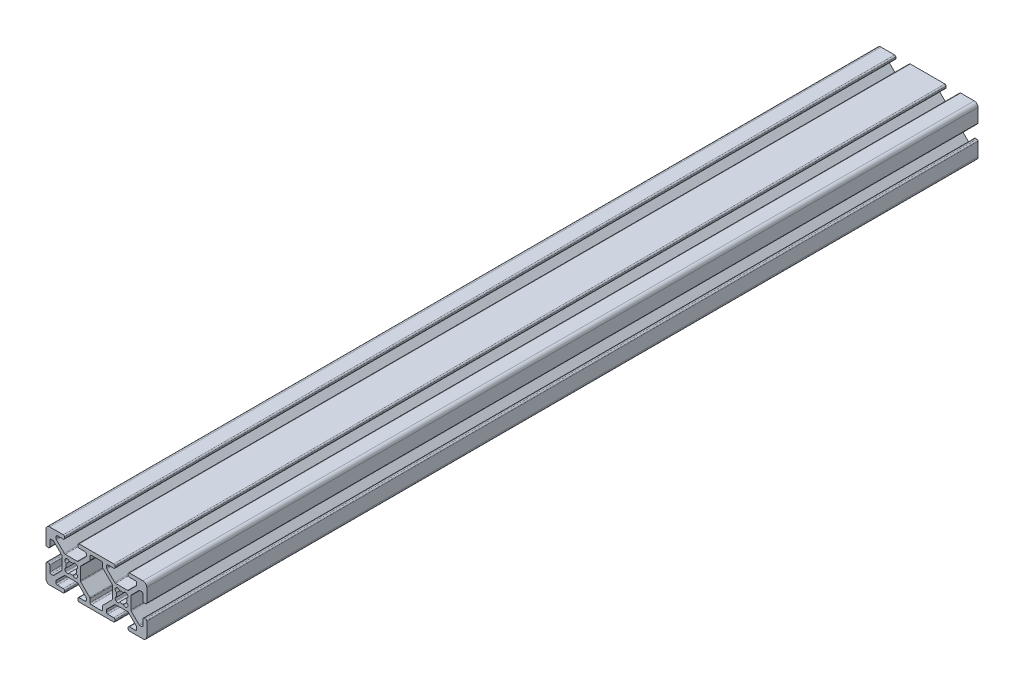
from build123d import *

# Parameters (mm, degrees)
EXTRUDE1_DEPTH = 330


with BuildPart() as part:
    # Sketch1 → Extrude1 (new body)
    with BuildSketch(Plane.XY):
        with BuildLine():
            Line((-22.383919339, -3.655), (-17.616080661, -3.655))
            ThreePointArc((-17.616080661, -3.655), (-17.421677478, -3.693669197), (-17.256870417, -3.803789755))
            Line((-17.256870417, -3.803789755), (-14.153789755, -6.906870417))
            ThreePointArc((-14.153789755, -6.906870417), (-14.043669197, -7.071677478), (-14.005, -7.266080661))
            Line((-14.005, -7.266080661), (-14.005, -7.992))
            ThreePointArc((-14.005, -7.992), (-14.153789755, -8.351210245), (-14.513, -8.5))
            Line((-14.513, -8.5), (-16.862, -8.5))
            ThreePointArc((-16.862, -8.5), (-17.221210245, -8.648789755), (-17.37, -9.008))
            Line((-17.37, -9.008), (-17.37, -9.492))
            ThreePointArc((-17.37, -9.492), (-17.221210245, -9.851210245), (-16.862, -10))
            Line((-16.862, -10), (-3.138, -10))
            ThreePointArc((-3.138, -10), (-2.778789755, -9.851210245), (-2.63, -9.492))
            Line((-2.63, -9.492), (-2.63, -9.008))
            ThreePointArc((-2.63, -9.008), (-2.778789755, -8.648789755), (-3.138, -8.5))
            Line((-3.138, -8.5), (-5.487, -8.5))
            ThreePointArc((-5.487, -8.5), (-5.846210245, -8.351210245), (-5.995, -7.992))
            Line((-5.995, -7.992), (-5.995, -7.266080661))
            ThreePointArc((-5.995, -7.266080661), (-5.956330803, -7.071677478), (-5.846210245, -6.906870417))
            Line((-5.846210245, -6.906870417), (-2.743129583, -3.803789755))
            ThreePointArc((-2.743129583, -3.803789755), (-2.578322522, -3.693669197), (-2.383919339, -3.655))
            Line((-2.383919339, -3.655), (2.383919339, -3.655))
            ThreePointArc((2.383919339, -3.655), (2.578322522, -3.693669197), (2.743129583, -3.803789755))
            Line((2.743129583, -3.803789755), (5.846210245, -6.906870417))
            ThreePointArc((5.846210245, -6.906870417), (5.956330803, -7.071677478), (5.995, -7.266080661))
            Line((5.995, -7.266080661), (5.995, -7.992))
            ThreePointArc((5.995, -7.992), (5.846210245, -8.351210245), (5.487, -8.5))
            Line((5.487, -8.5), (3.138, -8.5))
            ThreePointArc((3.138, -8.5), (2.778789755, -8.648789755), (2.63, -9.008))
            Line((2.63, -9.008), (2.63, -9.492))
            ThreePointArc((2.63, -9.492), (2.778789755, -9.851210245), (3.138, -10))
            Line((3.138, -10), (8.5, -10))
            ThreePointArc((8.5, -10), (9.560660172, -9.560660172), (10, -8.5))
            Line((10, -8.5), (10, -3.138))
            ThreePointArc((10, -3.138), (9.851210245, -2.778789755), (9.492, -2.63))
            Line((9.492, -2.63), (9.008, -2.63))
            ThreePointArc((9.008, -2.63), (8.648789755, -2.778789755), (8.5, -3.138))
            Line((8.5, -3.138), (8.5, -5.487))
            ThreePointArc((8.5, -5.487), (8.351210245, -5.846210245), (7.992, -5.995))
            Line((7.992, -5.995), (7.266080661, -5.995))
            ThreePointArc((7.266080661, -5.995), (7.071677478, -5.956330803), (6.906870417, -5.846210245))
            Line((6.906870417, -5.846210245), (3.803789755, -2.743129583))
            ThreePointArc((3.803789755, -2.743129583), (3.693669197, -2.578322522), (3.655, -2.383919339))
            Line((3.655, -2.383919339), (3.655, 2.383919339))
            ThreePointArc((3.655, 2.383919339), (3.693669197, 2.578322522), (3.803789755, 2.743129583))
            Line((3.803789755, 2.743129583), (6.906870417, 5.846210245))
            ThreePointArc((6.906870417, 5.846210245), (7.071677478, 5.956330803), (7.266080661, 5.995))
            Line((7.266080661, 5.995), (7.992, 5.995))
            ThreePointArc((7.992, 5.995), (8.351210245, 5.846210245), (8.5, 5.487))
            Line((8.5, 5.487), (8.5, 3.138))
            ThreePointArc((8.5, 3.138), (8.648789755, 2.778789755), (9.008, 2.63))
            Line((9.008, 2.63), (9.492, 2.63))
            ThreePointArc((9.492, 2.63), (9.851210245, 2.778789755), (10, 3.138))
            Line((10, 3.138), (10, 8.5))
            ThreePointArc((10, 8.5), (9.560660172, 9.560660172), (8.5, 10))
            Line((8.5, 10), (3.138, 10))
            ThreePointArc((3.138, 10), (2.778789755, 9.851210245), (2.63, 9.492))
            Line((2.63, 9.492), (2.63, 9.008))
            ThreePointArc((2.63, 9.008), (2.778789755, 8.648789755), (3.138, 8.5))
            Line((3.138, 8.5), (5.487, 8.5))
            ThreePointArc((5.487, 8.5), (5.846210245, 8.351210245), (5.995, 7.992))
            Line((5.995, 7.992), (5.995, 7.266080661))
            ThreePointArc((5.995, 7.266080661), (5.956330803, 7.071677478), (5.846210245, 6.906870417))
            Line((5.846210245, 6.906870417), (2.743129583, 3.803789755))
            ThreePointArc((2.743129583, 3.803789755), (2.578322522, 3.693669197), (2.383919339, 3.655))
            Line((2.383919339, 3.655), (-2.383919339, 3.655))
            ThreePointArc((-2.383919339, 3.655), (-2.578322522, 3.693669197), (-2.743129583, 3.803789755))
            Line((-2.743129583, 3.803789755), (-5.846210245, 6.906870417))
            ThreePointArc((-5.846210245, 6.906870417), (-5.956330803, 7.071677478), (-5.995, 7.266080661))
            Line((-5.995, 7.266080661), (-5.995, 7.992))
            ThreePointArc((-5.995, 7.992), (-5.846210245, 8.351210245), (-5.487, 8.5))
            Line((-5.487, 8.5), (-3.138, 8.5))
            ThreePointArc((-3.138, 8.5), (-2.778789755, 8.648789755), (-2.63, 9.008))
            Line((-2.63, 9.008), (-2.63, 9.492))
            ThreePointArc((-2.63, 9.492), (-2.778789755, 9.851210245), (-3.138, 10))
            Line((-3.138, 10), (-16.862, 10))
            ThreePointArc((-16.862, 10), (-17.221210245, 9.851210245), (-17.37, 9.492))
            Line((-17.37, 9.492), (-17.37, 9.008))
            ThreePointArc((-17.37, 9.008), (-17.221210245, 8.648789755), (-16.862, 8.5))
            Line((-16.862, 8.5), (-14.513, 8.5))
            ThreePointArc((-14.513, 8.5), (-14.153789755, 8.351210245), (-14.005, 7.992))
            Line((-14.005, 7.992), (-14.005, 7.266080661))
            ThreePointArc((-14.005, 7.266080661), (-14.043669197, 7.071677478), (-14.153789755, 6.906870417))
            Line((-14.153789755, 6.906870417), (-17.256870417, 3.803789755))
            ThreePointArc((-17.256870417, 3.803789755), (-17.421677478, 3.693669197), (-17.616080661, 3.655))
            Line((-17.616080661, 3.655), (-22.383919339, 3.655))
            ThreePointArc((-22.383919339, 3.655), (-22.578322522, 3.693669197), (-22.743129583, 3.803789755))
            Line((-22.743129583, 3.803789755), (-25.846210245, 6.906870417))
            ThreePointArc((-25.846210245, 6.906870417), (-25.956330803, 7.071677478), (-25.995, 7.266080661))
            Line((-25.995, 7.266080661), (-25.995, 7.992))
            ThreePointArc((-25.995, 7.992), (-25.846210245, 8.351210245), (-25.487, 8.5))
            Line((-25.487, 8.5), (-23.138, 8.5))
            ThreePointArc((-23.138, 8.5), (-22.778789755, 8.648789755), (-22.63, 9.008))
            Line((-22.63, 9.008), (-22.63, 9.492))
            ThreePointArc((-22.63, 9.492), (-22.778789755, 9.851210245), (-23.138, 10))
            Line((-23.138, 10), (-28.5, 10))
            ThreePointArc((-28.5, 10), (-29.560660172, 9.560660172), (-30, 8.5))
            Line((-30, 8.5), (-30, 3.138))
            ThreePointArc((-30, 3.138), (-29.851210245, 2.778789755), (-29.492, 2.63))
            Line((-29.492, 2.63), (-29.008, 2.63))
            ThreePointArc((-29.008, 2.63), (-28.648789755, 2.778789755), (-28.5, 3.138))
            Line((-28.5, 3.138), (-28.5, 5.487))
            ThreePointArc((-28.5, 5.487), (-28.351210245, 5.846210245), (-27.992, 5.995))
            Line((-27.992, 5.995), (-27.266080661, 5.995))
            ThreePointArc((-27.266080661, 5.995), (-27.071677478, 5.956330803), (-26.906870417, 5.846210245))
            Line((-26.906870417, 5.846210245), (-23.803789755, 2.743129583))
            ThreePointArc((-23.803789755, 2.743129583), (-23.693669197, 2.578322522), (-23.655, 2.383919339))
            Line((-23.655, 2.383919339), (-23.655, -2.383919339))
            ThreePointArc((-23.655, -2.383919339), (-23.693669197, -2.578322522), (-23.803789755, -2.743129583))
            Line((-23.803789755, -2.743129583), (-26.906870417, -5.846210245))
            ThreePointArc((-26.906870417, -5.846210245), (-27.071677478, -5.956330803), (-27.266080661, -5.995))
            Line((-27.266080661, -5.995), (-27.992, -5.995))
            ThreePointArc((-27.992, -5.995), (-28.351210245, -5.846210245), (-28.5, -5.487))
            Line((-28.5, -5.487), (-28.5, -3.138))
            ThreePointArc((-28.5, -3.138), (-28.648789755, -2.778789755), (-29.008, -2.63))
            Line((-29.008, -2.63), (-29.492, -2.63))
            ThreePointArc((-29.492, -2.63), (-29.851210245, -2.778789755), (-30, -3.138))
            Line((-30, -3.138), (-30, -8.5))
            ThreePointArc((-30, -8.5), (-29.560660172, -9.560660172), (-28.5, -10))
            Line((-28.5, -10), (-23.138, -10))
            ThreePointArc((-23.138, -10), (-22.778789755, -9.851210245), (-22.63, -9.492))
            Line((-22.63, -9.492), (-22.63, -9.008))
            ThreePointArc((-22.63, -9.008), (-22.778789755, -8.648789755), (-23.138, -8.5))
            Line((-23.138, -8.5), (-25.487, -8.5))
            ThreePointArc((-25.487, -8.5), (-25.846210245, -8.351210245), (-25.995, -7.992))
            Line((-25.995, -7.992), (-25.995, -7.266080661))
            ThreePointArc((-25.995, -7.266080661), (-25.956330803, -7.071677478), (-25.846210245, -6.906870417))
            Line((-25.846210245, -6.906870417), (-22.743129583, -3.803789755))
            ThreePointArc((-22.743129583, -3.803789755), (-22.578322522, -3.693669197), (-22.383919339, -3.655))
        make_face()
        with BuildLine():
            Line((-2.124900844, -2.304505966), (-2.304505966, -2.124900844))
            ThreePointArc((-2.304505966, -2.124900844), (-2.505938017, -1.356467811), (-1.935133506, -0.803976718))
            ThreePointArc((-1.935133506, -0.803976718), (-2.0955, 0), (-1.935133506, 0.803976718))
            ThreePointArc((-1.935133506, 0.803976718), (-2.505938017, 1.356467811), (-2.304505966, 2.124900844))
            Line((-2.304505966, 2.124900844), (-2.124900844, 2.304505966))
            ThreePointArc((-2.124900844, 2.304505966), (-1.356467811, 2.505938017), (-0.803976718, 1.935133506))
            ThreePointArc((-0.803976718, 1.935133506), (0, 2.0955), (0.803976718, 1.935133506))
            ThreePointArc((0.803976718, 1.935133506), (1.356467811, 2.505938017), (2.124900844, 2.304505966))
            Line((2.124900844, 2.304505966), (2.304505966, 2.124900844))
            ThreePointArc((2.304505966, 2.124900844), (2.505938017, 1.356467811), (1.935133506, 0.803976718))
            ThreePointArc((1.935133506, 0.803976718), (2.0955, 0), (1.935133506, -0.803976718))
            ThreePointArc((1.935133506, -0.803976718), (2.505938017, -1.356467811), (2.304505966, -2.124900844))
            Line((2.304505966, -2.124900844), (2.124900844, -2.304505966))
            ThreePointArc((2.124900844, -2.304505966), (1.356467811, -2.505938017), (0.803976718, -1.935133506))
            ThreePointArc((0.803976718, -1.935133506), (0, -2.0955), (-0.803976718, -1.935133506))
            ThreePointArc((-0.803976718, -1.935133506), (-1.356467811, -2.505938017), (-2.124900844, -2.304505966))
        make_face(mode=Mode.SUBTRACT)
        with BuildLine():
            Line((-12.505, -7.992), (-12.505, -6.644760318))
            ThreePointArc((-12.505, -6.644760318), (-12.543669197, -6.450357134), (-12.653789755, -6.285550073))
            Line((-12.653789755, -6.285550073), (-16.196210245, -2.743129583))
            ThreePointArc((-16.196210245, -2.743129583), (-16.306330803, -2.578322522), (-16.345, -2.383919339))
            Line((-16.345, -2.383919339), (-16.345, 2.383919339))
            ThreePointArc((-16.345, 2.383919339), (-16.306330803, 2.578322522), (-16.196210245, 2.743129583))
            Line((-16.196210245, 2.743129583), (-12.653789755, 6.285550073))
            ThreePointArc((-12.653789755, 6.285550073), (-12.543669197, 6.450357134), (-12.505, 6.644760318))
            Line((-12.505, 6.644760318), (-12.505, 7.992))
            ThreePointArc((-12.505, 7.992), (-12.356210245, 8.351210245), (-11.997, 8.5))
            Line((-11.997, 8.5), (-8.003, 8.5))
            ThreePointArc((-8.003, 8.5), (-7.643789755, 8.351210245), (-7.495, 7.992))
            Line((-7.495, 7.992), (-7.495, 6.644760318))
            ThreePointArc((-7.495, 6.644760318), (-7.456330803, 6.450357134), (-7.346210245, 6.285550073))
            Line((-7.346210245, 6.285550073), (-3.803789755, 2.743129583))
            ThreePointArc((-3.803789755, 2.743129583), (-3.693669197, 2.578322522), (-3.655, 2.383919339))
            Line((-3.655, 2.383919339), (-3.655, -2.383919339))
            ThreePointArc((-3.655, -2.383919339), (-3.693669197, -2.578322522), (-3.803789755, -2.743129583))
            Line((-3.803789755, -2.743129583), (-7.346210245, -6.285550073))
            ThreePointArc((-7.346210245, -6.285550073), (-7.456330803, -6.450357134), (-7.495, -6.644760318))
            Line((-7.495, -6.644760318), (-7.495, -7.992))
            ThreePointArc((-7.495, -7.992), (-7.643789755, -8.351210245), (-8.003, -8.5))
            Line((-8.003, -8.5), (-11.997, -8.5))
            ThreePointArc((-11.997, -8.5), (-12.356210245, -8.351210245), (-12.505, -7.992))
        make_face(mode=Mode.SUBTRACT)
        with BuildLine():
            Line((-22.124900844, -2.304505966), (-22.304505966, -2.124900844))
            ThreePointArc((-22.304505966, -2.124900844), (-22.505938017, -1.356467811), (-21.935133506, -0.803976718))
            ThreePointArc((-21.935133506, -0.803976718), (-22.0955, 0), (-21.935133506, 0.803976718))
            ThreePointArc((-21.935133506, 0.803976718), (-22.505938017, 1.356467811), (-22.304505966, 2.124900844))
            Line((-22.304505966, 2.124900844), (-22.124900844, 2.304505966))
            ThreePointArc((-22.124900844, 2.304505966), (-21.356467811, 2.505938017), (-20.803976718, 1.935133506))
            ThreePointArc((-20.803976718, 1.935133506), (-20, 2.0955), (-19.196023282, 1.935133506))
            ThreePointArc((-19.196023282, 1.935133506), (-18.643532189, 2.505938017), (-17.875099156, 2.304505966))
            Line((-17.875099156, 2.304505966), (-17.695494034, 2.124900844))
            ThreePointArc((-17.695494034, 2.124900844), (-17.494061983, 1.356467811), (-18.064866494, 0.803976718))
            ThreePointArc((-18.064866494, 0.803976718), (-17.9045, 0), (-18.064866494, -0.803976718))
            ThreePointArc((-18.064866494, -0.803976718), (-17.494061983, -1.356467811), (-17.695494034, -2.124900844))
            Line((-17.695494034, -2.124900844), (-17.875099156, -2.304505966))
            ThreePointArc((-17.875099156, -2.304505966), (-18.643532189, -2.505938017), (-19.196023282, -1.935133506))
            ThreePointArc((-19.196023282, -1.935133506), (-20, -2.0955), (-20.803976718, -1.935133506))
            ThreePointArc((-20.803976718, -1.935133506), (-21.356467811, -2.505938017), (-22.124900844, -2.304505966))
        make_face(mode=Mode.SUBTRACT)
    extrude(amount=-EXTRUDE1_DEPTH)


solid = part.part
